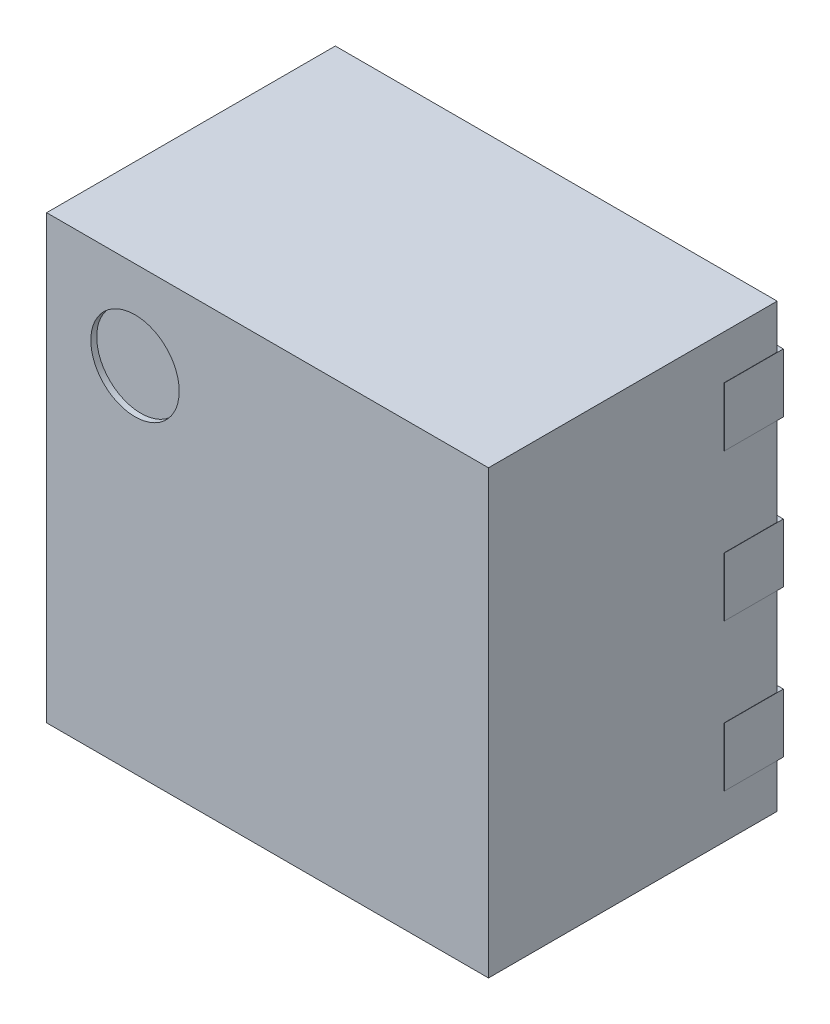
from build123d import *

# Parameters (mm, degrees)
SKETCH1_W           = 1.5
SKETCH1_H           = 1.5
BOSS_EXTRUDE1_DEPTH = 0.98
SKETCH2_R           = 0.15
CUT_EXTRUDE1_DEPTH  = 0.02
BOSS_EXTRUDE2_DEPTH = 0.2


with BuildPart() as part:
    # Sketch1 → Boss-Extrude1 (new body)
    with BuildSketch(Plane.XY):
        Rectangle(SKETCH1_W, SKETCH1_H)
    extrude(amount=BOSS_EXTRUDE1_DEPTH)

    # Sketch2 → Cut-Extrude1 (cut)
    with BuildSketch(Plane.XY.offset(0.98)):
        with Locations((-0.45, 0.45)):
            Circle(SKETCH2_R)
    extrude(amount=-CUT_EXTRUDE1_DEPTH, mode=Mode.SUBTRACT)

    # Sketch3 → Boss-Extrude2 (add)
    with BuildSketch(Plane.XY.offset(-0.02)):
        with BuildLine():
            Line((-0.751, 0.625), (-0.751, 0.375))
            Line((-0.751, 0.375), (-0.475, 0.375))
            ThreePointArc((-0.475, 0.375), (-0.35, 0.5), (-0.475, 0.625))
            Line((-0.475, 0.625), (-0.751, 0.625))
        make_face()
        with BuildLine():
            Line((-0.751, -0.625), (-0.475, -0.625))
            ThreePointArc((-0.475, -0.625), (-0.35, -0.5), (-0.475, -0.375))
            Line((-0.475, -0.375), (-0.751, -0.375))
            Line((-0.751, -0.375), (-0.751, -0.625))
        make_face()
        with BuildLine():
            Line((-0.751, 0.125), (-0.751, -0.125))
            Line((-0.751, -0.125), (-0.475, -0.125))
            ThreePointArc((-0.475, -0.125), (-0.35, 0), (-0.475, 0.125))
            Line((-0.475, 0.125), (-0.751, 0.125))
        make_face()
        with BuildLine():
            Line((0.751, 0.6), (0.751, 0.4))
            Line((0.751, 0.4), (0.05, 0.4))
            ThreePointArc((0.05, 0.4), (-0.05, 0.5), (0.05, 0.6))
            Line((0.05, 0.6), (0.751, 0.6))
        make_face()
        with BuildLine():
            Line((0.751, -0.6), (0.05, -0.6))
            ThreePointArc((0.05, -0.6), (-0.05, -0.5), (0.05, -0.4))
            Line((0.05, -0.4), (0.751, -0.4))
            Line((0.751, -0.4), (0.751, -0.6))
        make_face()
        with BuildLine():
            Line((0.751, 0.1), (0.751, -0.1))
            Line((0.751, -0.1), (0.05, -0.1))
            ThreePointArc((0.05, -0.1), (-0.05, 0), (0.05, 0.1))
            Line((0.05, 0.1), (0.751, 0.1))
        make_face()
    extrude(amount=BOSS_EXTRUDE2_DEPTH)


solid = part.part
